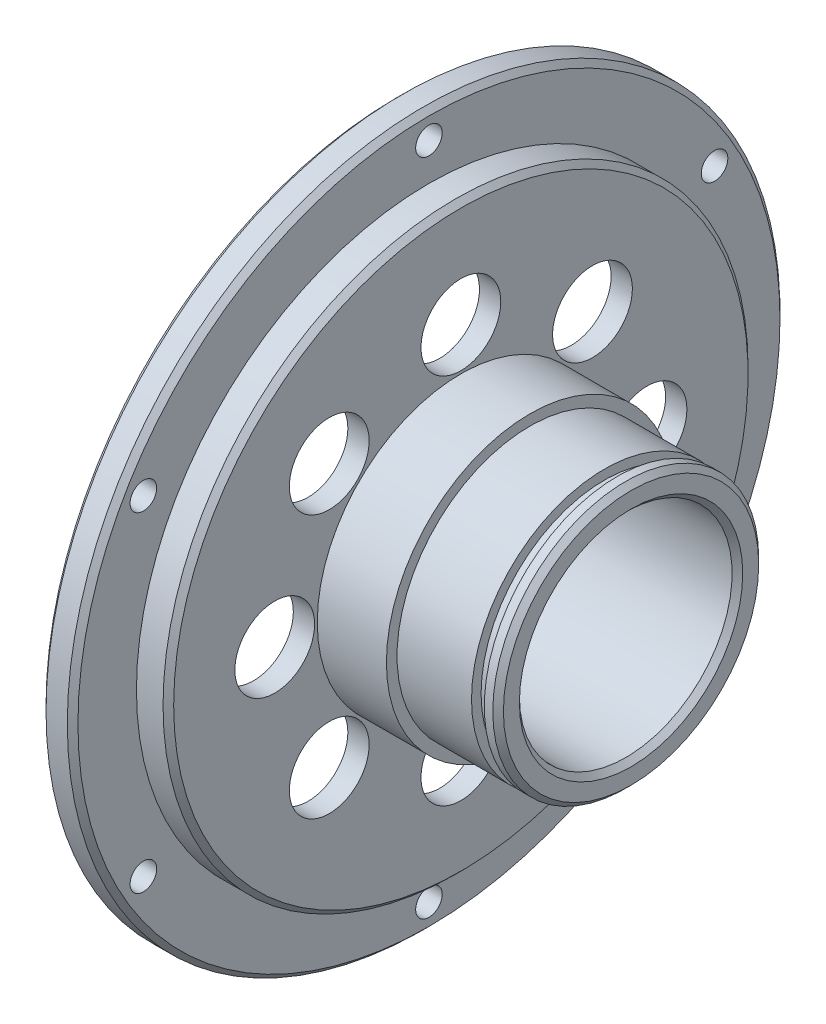
from build123d import *

# Parameters (mm, degrees)
CHAMFER_1_SIZE           = 0.5
SKETCH_2_R               = 3.75
CUT_EXTRUDE_1_DEPTH      = 10
PATTERN_CIRCULAR_1_COUNT = 6
SKETCH_6_OUTSIDE_W       = 88.454
SKETCH_6_OUTSIDE_H       = 88.454
SKETCH_6_OUTSIDE_R       = 12.5
CUT_EXTRUDE_2_DEPTH      = 9.5
CHAMFER_2_SIZE           = 0.5


with BuildPart() as part:
    # 草图1 → 旋转1 (revolve)
    with BuildSketch(Plane.XY):
        Polygon((0, 33.5), (0, 25.5), (4, 25.5), (4, 9), (6, 9), (6, 10), (22, 10), (22, 13.5), (20.7, 13.5), (20.7, 11.6), (19.5, 11.6), (19.5, 13.5), (6, 13.5), (6, 27.5), (3, 27.5), (3, 33.5), align=None)
    revolve(axis=Axis((0, 0, 0), (1, 0, 0)))

    # 倒角1
    chamfer_1_edges = [part.edges().sort_by_distance(p)[0] for p in [
        (3, -33.5, 0),
        (6, -27.5, 0),
        (22, -13.5, 0),
        (22, -10, 0),
        (4, -9, 0),
        (0, -25.5, 0),
        (0, -33.5, 0),
    ]]
    chamfer(chamfer_1_edges, length=CHAMFER_1_SIZE)

    # 草图2 → 切除-拉伸1 (cut)
    with BuildSketch(Plane(origin=(6, 0, 0), x_dir=(0, 0, -1), z_dir=(1, 0, 0))):
        with Locations((0, -17.5)):
            Circle(SKETCH_2_R)
        with Locations((0, 17.5)):
            Circle(SKETCH_2_R)
        with Locations((12.374368671, 12.374368671)):
            Circle(SKETCH_2_R)
        with Locations((17.5, 0)):
            Circle(SKETCH_2_R)
        with Locations((12.374368671, -12.374368671)):
            Circle(SKETCH_2_R)
        with Locations((-12.374368671, -12.374368671)):
            Circle(SKETCH_2_R)
        with Locations((-17.5, 0)):
            Circle(SKETCH_2_R)
        with Locations((-12.374368671, 12.374368671)):
            Circle(SKETCH_2_R)
    extrude(amount=-CUT_EXTRUDE_1_DEPTH, mode=Mode.SUBTRACT)

    # 草图5 → M3 螺纹孔1 (revolve, cut)
    with BuildSketch(Plane(origin=(3, 31, 0), x_dir=(0, 0, -1), z_dir=(0, 1, 0))):
        Polygon((0, 0), (0, 8.251075774), (1.25, 7.5), (1.25, 0), align=None)
    hole_wizard_m3_1 = revolve(axis=Axis((9.35, 31, 0), (-1, 0, 0)), mode=Mode.SUBTRACT)

    # 阵列(圆周)1: M3 螺纹孔1 ×6 about axis
    pattern_circular_1_axis = Axis((0, 0, 0), (1, 0, 0))
    for i in range(1, PATTERN_CIRCULAR_1_COUNT):
        add(hole_wizard_m3_1.rotate(pattern_circular_1_axis, i * 360 / PATTERN_CIRCULAR_1_COUNT), mode=Mode.SUBTRACT)

    # 草图6 outside → 切除-拉伸2 (cut)
    with BuildSketch(Plane(origin=(22, 0, 0), x_dir=(0, 0, -1), z_dir=(1, 0, 0))):
        Rectangle(SKETCH_6_OUTSIDE_W, SKETCH_6_OUTSIDE_H)
        Circle(SKETCH_6_OUTSIDE_R, mode=Mode.SUBTRACT)
    extrude(amount=-CUT_EXTRUDE_2_DEPTH, mode=Mode.SUBTRACT)

    # 倒角2
    chamfer_2_edges = [part.edges().sort_by_distance(p)[0] for p in [
        (22, 0, 12.5),
    ]]
    chamfer(chamfer_2_edges, length=CHAMFER_2_SIZE)


solid = part.part
